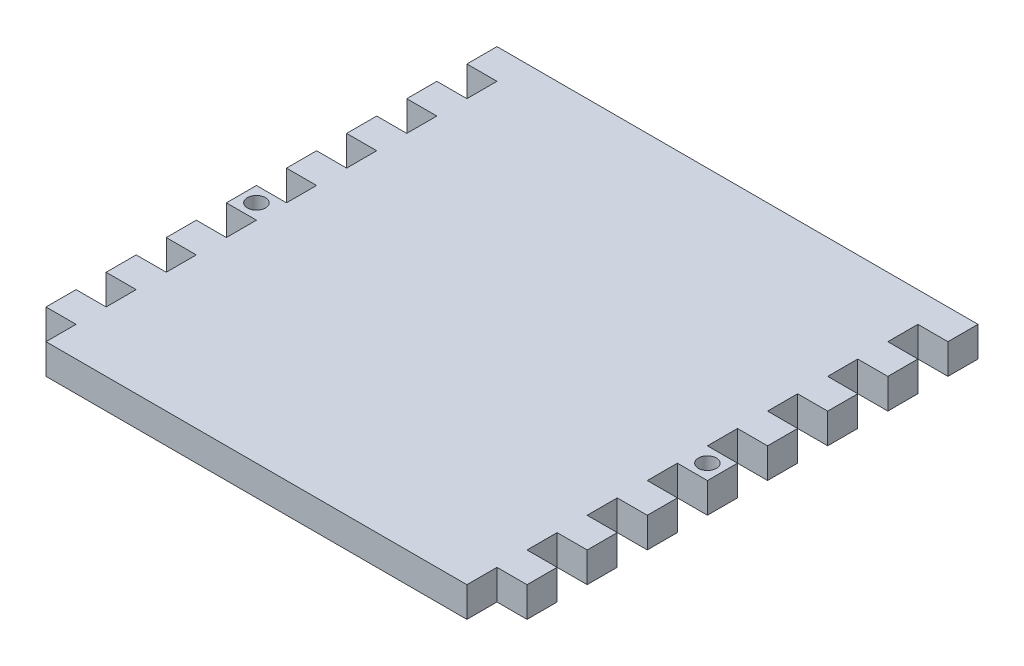
from build123d import *

# Parameters (mm, degrees)
ESQUISSE1_W                     = 70
ESQUISSE1_H                     = 80
BOSS_EXTRU_1_DEPTH              = 5
ESQUISSE2_W                     = 5
ESQUISSE2_H                     = 5
BOSS_EXTRU_2_DEPTH              = 5
R_P_TITION_LIN_AIRE1_COUNT      = 2
R_P_TITION_LIN_AIRE1_PITCH      = 75
R_P_TITION_LIN_AIRE1_COUNT_DIR2 = 8
R_P_TITION_LIN_AIRE1_PITCH_DIR2 = 10
ESQUISSE3_R                     = 1.5
ENL_V_MAT_EXTRU_1_DEPTH         = 10


with BuildPart() as part:
    # Esquisse1 → Boss.-Extru.1 (new body)
    with BuildSketch(Plane(origin=(0, 0, 0), x_dir=(1, 0, 0), z_dir=(0, 1, 0))):
        Rectangle(ESQUISSE1_W, ESQUISSE1_H)
    extrude(amount=BOSS_EXTRU_1_DEPTH)

    # Esquisse2 → Boss.-Extru.2 (add)
    with BuildSketch(Plane(origin=(0, 5, 0), x_dir=(1, 0, 0), z_dir=(0, 1, 0))):
        with Locations((-37.5, 37.5)):
            Rectangle(ESQUISSE2_W, ESQUISSE2_H)
    boss_extru_2 = extrude(amount=-BOSS_EXTRU_2_DEPTH)

    # Répétition linéaire1: Boss.-Extru.2 2 × 8
    with Locations(*[(i * R_P_TITION_LIN_AIRE1_PITCH, 0, j * R_P_TITION_LIN_AIRE1_PITCH_DIR2) for i in range(R_P_TITION_LIN_AIRE1_COUNT) for j in range(R_P_TITION_LIN_AIRE1_COUNT_DIR2) if (i, j) != (0, 0)]):
        add(boss_extru_2)

    # Esquisse3 → Enlèv. mat.-Extru.1 (cut)
    with BuildSketch(Plane(origin=(0, 5, 0), x_dir=(1, 0, 0), z_dir=(0, 1, 0))):
        with Locations((-37.5, -2.5)):
            Circle(ESQUISSE3_R)
    enl_v_mat_extru_1 = extrude(amount=-ENL_V_MAT_EXTRU_1_DEPTH, mode=Mode.SUBTRACT)

    # Symétrie1: Enlèv. mat.-Extru.1 across plane
    add(enl_v_mat_extru_1.mirror(Plane(origin=(0, 0, 0), x_dir=(0, 0, 1), z_dir=(1, 0, 0))), mode=Mode.SUBTRACT)


solid = part.part
